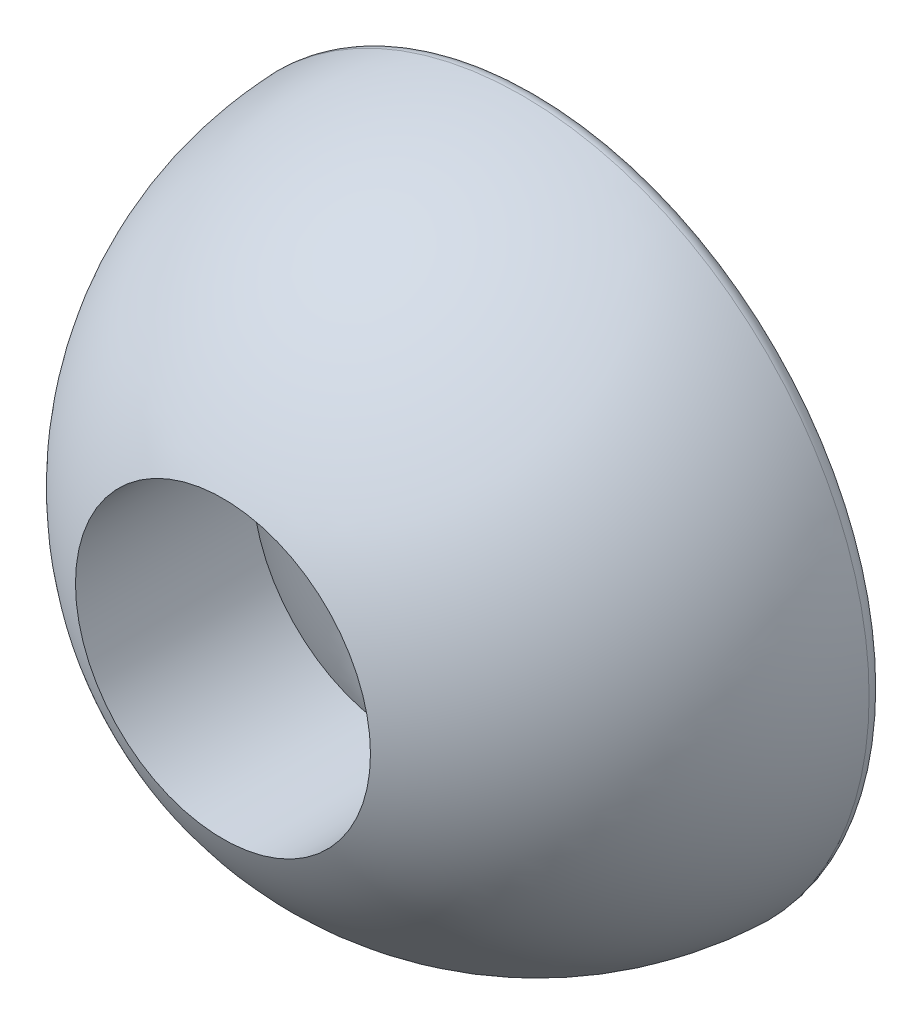
from build123d import *

# Parameters (mm, degrees)
BOTTOM_FILLET_R = 0.4


with BuildPart() as part:
    # Sketch2 → Main Body (revolve)
    with BuildSketch(Plane(origin=(0, 0, 0), x_dir=(1, 0, 0), z_dir=(0, 1, 0))):
        with BuildLine():
            Line((5.6, 0), (9.65, 0))
            ThreePointArc((9.65, 0), (8.145167279, -5.174818837), (4.1, -8.735702605))
            Line((4.1, -8.735702605), (4.1, -3.814446225))
            ThreePointArc((4.1, -3.814446225), (5.211525688, -2.049390153), (5.6, 0))
        make_face()
    revolve(axis=Axis((0, 0, 0), (0, 0, 1)))

    # Bottom Fillet
    bottom_fillet_edges = [part.edges().sort_by_distance(p)[0] for p in [
        (-9.65, 0, 0),
        (-5.6, 0, 0),
    ]]
    fillet(bottom_fillet_edges, radius=BOTTOM_FILLET_R)


solid = part.part
